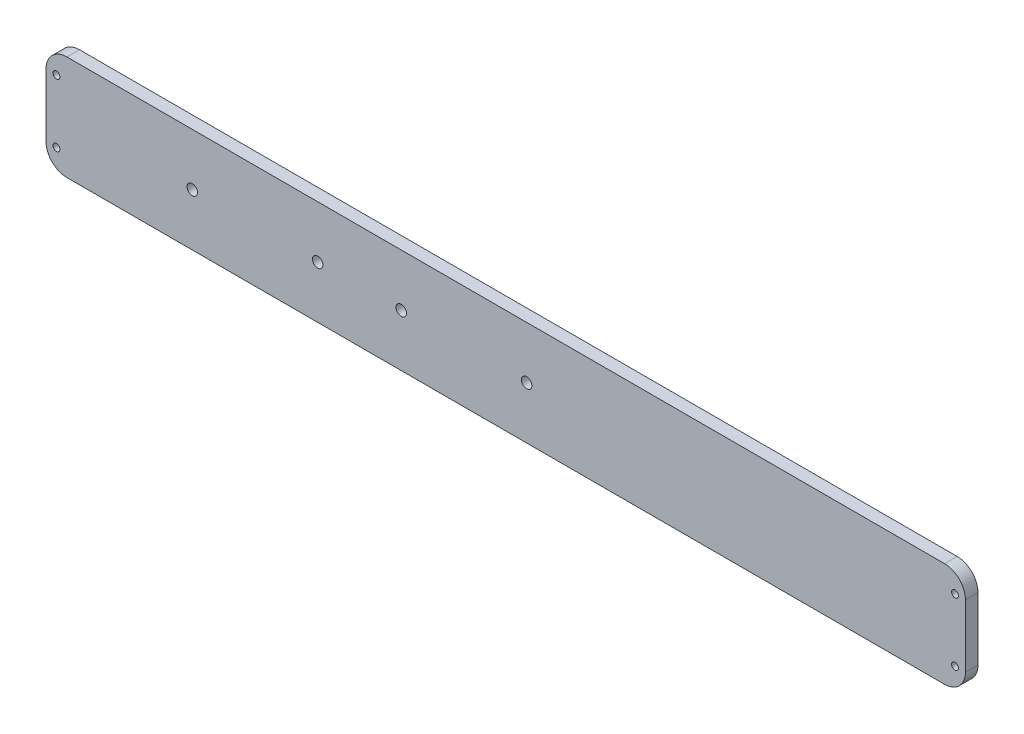
from build123d import *

# Parameters (mm, degrees)
BOSS_EXTRU_1_DEPTH                            = 6
ESQUISSE2_R                                   = 1.65
ESQUISSE2_R_2                                 = 2.5
ENL_V_MAT_EXTRU_1_DEPTH                       = 6
TROU_POUR_TARAUDAGE_POUR_TROU_TARAUD_M6_D     = 5
TROU_POUR_TARAUDAGE_POUR_TROU_TARAUD_M6_DEPTH = 15
TROU_POUR_TARAUDAGE_POUR_TROU_TARAUD_M6_TIP   = 1.502151548
TROU_POUR_TARAUDAGE_POUR_TROU_TARAUD_M4_D     = 3.3
TROU_POUR_TARAUDAGE_POUR_TROU_TARAUD_M4_DEPTH = 15
TROU_POUR_TARAUDAGE_POUR_TROU_TARAUD_M4_TIP   = 0.991420021


with BuildPart() as part:
    # Esquisse1 → Boss.-Extru.1 (new body)
    with BuildSketch(Plane.XY):
        with BuildLine():
            Line((210, -25), (-210, -25))
            ThreePointArc((-210, -25), (-217.071067812, -22.071067812), (-220, -15))
            Line((-220, -15), (-220, 15))
            ThreePointArc((-220, 15), (-217.071067812, 22.071067812), (-210, 25))
            Line((-210, 25), (210, 25))
            ThreePointArc((210, 25), (217.071067812, 22.071067812), (220, 15))
            Line((220, 15), (220, -15))
            ThreePointArc((220, -15), (217.071067812, -22.071067812), (210, -25))
        make_face()
    extrude(amount=BOSS_EXTRU_1_DEPTH)

    # Esquisse2 → Enlèv. mat.-Extru.1 (cut)
    with BuildSketch(Plane.XY.offset(6)):
        with Locations((215, 15)):
            Circle(ESQUISSE2_R)
        with Locations((215, -15)):
            Circle(ESQUISSE2_R)
        with Locations((-215, 15)):
            Circle(ESQUISSE2_R)
        with Locations((-215, -15)):
            Circle(ESQUISSE2_R)
        with Locations((-150, 0)):
            Circle(ESQUISSE2_R_2)
        with Locations((-90, 0)):
            Circle(ESQUISSE2_R_2)
        with Locations((-50, 0)):
            Circle(ESQUISSE2_R_2)
        with Locations((10, 0)):
            Circle(ESQUISSE2_R_2)
    extrude(amount=-ENL_V_MAT_EXTRU_1_DEPTH, mode=Mode.SUBTRACT)

    # Trou pour taraudage pour trou taraudé M6x1.01
    with Locations(Plane(origin=(-150, 0, 6), x_dir=(1, 0, 0), z_dir=(0, 0, 1))):
        with Locations((0, 0), (60, 0), (100, 0), (160, 0)):
            Hole(TROU_POUR_TARAUDAGE_POUR_TROU_TARAUD_M6_D / 2, depth=TROU_POUR_TARAUDAGE_POUR_TROU_TARAUD_M6_DEPTH)
            with Locations((0, 0, -(TROU_POUR_TARAUDAGE_POUR_TROU_TARAUD_M6_DEPTH + TROU_POUR_TARAUDAGE_POUR_TROU_TARAUD_M6_TIP / 2))):  # 118° drill point
                Cone(0, TROU_POUR_TARAUDAGE_POUR_TROU_TARAUD_M6_D / 2, TROU_POUR_TARAUDAGE_POUR_TROU_TARAUD_M6_TIP, mode=Mode.SUBTRACT)

    # Trou pour taraudage pour trou taraudé M4x0.71
    with Locations(Plane(origin=(-215, 15, 6), x_dir=(1, 0, 0), z_dir=(0, 0, 1))):
        with Locations((0, 0), (0, -30), (430, 0), (430, -30)):
            Hole(TROU_POUR_TARAUDAGE_POUR_TROU_TARAUD_M4_D / 2, depth=TROU_POUR_TARAUDAGE_POUR_TROU_TARAUD_M4_DEPTH)
            with Locations((0, 0, -(TROU_POUR_TARAUDAGE_POUR_TROU_TARAUD_M4_DEPTH + TROU_POUR_TARAUDAGE_POUR_TROU_TARAUD_M4_TIP / 2))):  # 118° drill point
                Cone(0, TROU_POUR_TARAUDAGE_POUR_TROU_TARAUD_M4_D / 2, TROU_POUR_TARAUDAGE_POUR_TROU_TARAUD_M4_TIP, mode=Mode.SUBTRACT)


solid = part.part
